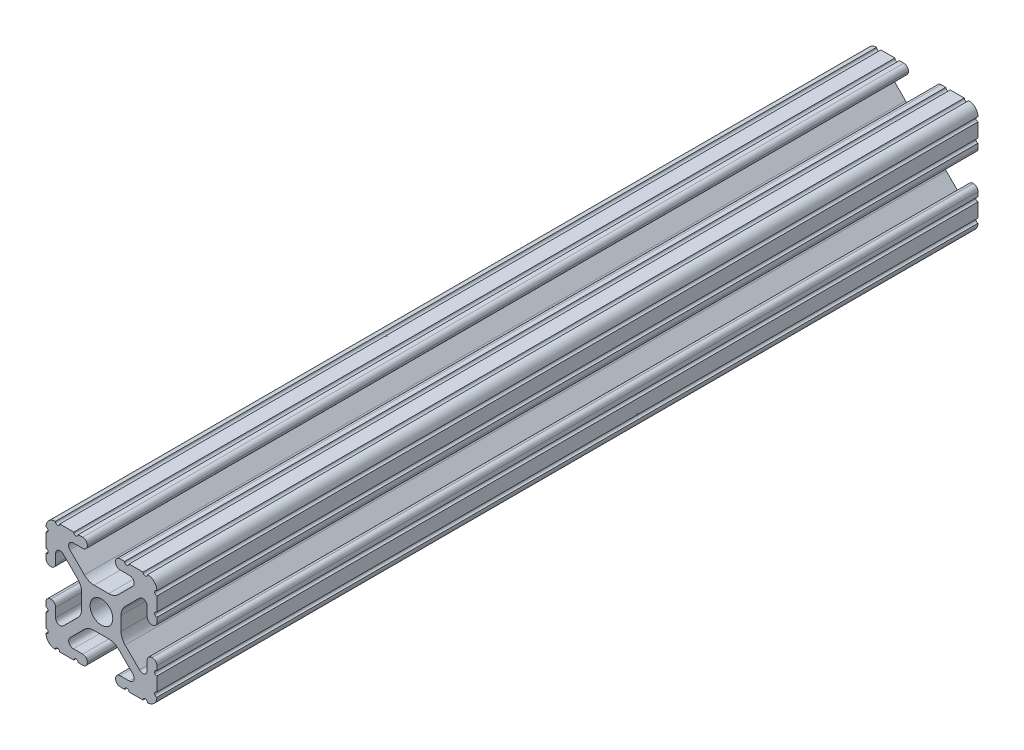
from build123d import *

# Parameters (mm, degrees)
SKETCH1_R               = 2.6035
BOSS_EXTRUDE1_DEPTH     = 304.8
SKETCH2_W               = 16.257599062
SKETCH2_H               = 27.586789262
CUT_EXTRUDE1_DEPTH      = 1.778
CUT_EXTRUDE1_DEPTH_BACK = 26.162


with BuildPart() as part:
    # Sketch1 → Boss-Extrude1 (new body, symmetric)
    with BuildSketch(Plane.XY):
        with BuildLine():
            Line((-7.179650497, -8.645192506), (-3.952270251, -5.423690499))
            ThreePointArc((-3.952270251, -5.423690499), (-2.922936451, -4.736929036), (-1.709253557, -4.4958))
            Line((-1.709253557, -4.4958), (1.709253557, -4.4958))
            ThreePointArc((1.709253557, -4.4958), (2.922936451, -4.736929036), (3.952270251, -5.423690499))
            Line((3.952270251, -5.423690499), (7.179650497, -8.645192506))
            ThreePointArc((7.179650497, -8.645192506), (7.41473083, -9.822813117), (6.416408329, -10.4902))
            Line((6.416408329, -10.4902), (4.287512407, -10.4902))
            ThreePointArc((4.287512407, -10.4902), (3.54574862, -10.79744862), (3.2385, -11.539212407))
            Line((3.2385, -11.539212407), (3.2385, -11.650987593))
            ThreePointArc((3.2385, -11.650987593), (3.54574862, -12.39275138), (4.287512407, -12.7))
            Line((4.287512407, -12.7), (5.317126718, -12.7))
            ThreePointArc((5.317126718, -12.7), (5.825126718, -12.192), (6.333126718, -12.7))
            Line((6.333126718, -12.7), (9.550443118, -12.7))
            ThreePointArc((9.550443118, -12.7), (10.058366869, -12.192000006), (10.566443095, -12.699847501))
            ThreePointArc((10.566443095, -12.699847501), (12.082537762, -12.08250727), (12.699846982, -10.566399977))
            ThreePointArc((12.699846982, -10.566399977), (12.192000006, -10.058323491), (12.7, -9.5504))
            Line((12.7, -9.5504), (12.7, -6.3330836))
            ThreePointArc((12.7, -6.3330836), (12.192, -5.8250836), (12.7, -5.3170836))
            Line((12.7, -5.3170836), (12.7, -4.287469289))
            ThreePointArc((12.7, -4.287469289), (12.39275138, -3.545705502), (11.650987593, -3.238456882))
            Line((11.650987593, -3.238456882), (11.539212407, -3.238456882))
            ThreePointArc((11.539212407, -3.238456882), (10.79744862, -3.545705502), (10.4902, -4.287469289))
            Line((10.4902, -4.287469289), (10.4902, -6.402089023))
            ThreePointArc((10.4902, -6.402089023), (9.856505071, -7.351067942), (8.737131347, -7.129408934))
            Line((8.737131347, -7.129408934), (5.441005833, -3.840816462))
            ThreePointArc((5.441005833, -3.840816462), (4.750877967, -2.809883091), (4.5085, -1.593185507))
            Line((4.5085, -1.593185507), (4.5085, 1.593185507))
            ThreePointArc((4.5085, 1.593185507), (4.750877967, 2.809883091), (5.441005833, 3.840816462))
            Line((5.441005833, 3.840816462), (8.737131347, 7.129408934))
            ThreePointArc((8.737131347, 7.129408934), (9.856505071, 7.351067942), (10.4902, 6.402089023))
            Line((10.4902, 6.402089023), (10.4902, 4.287469289))
            ThreePointArc((10.4902, 4.287469289), (10.79744862, 3.545705502), (11.539212407, 3.238456882))
            Line((11.539212407, 3.238456882), (11.650987593, 3.238456882))
            ThreePointArc((11.650987593, 3.238456882), (12.39275138, 3.545705502), (12.7, 4.287469289))
            Line((12.7, 4.287469289), (12.7, 5.3170836))
            ThreePointArc((12.7, 5.3170836), (12.192, 5.8250836), (12.7, 6.3330836))
            Line((12.7, 6.3330836), (12.7, 9.5504))
            ThreePointArc((12.7, 9.5504), (12.192000006, 10.058323491), (12.699846982, 10.566399977))
            ThreePointArc((12.699846982, 10.566399977), (12.082537762, 12.08250727), (10.566443095, 12.699847501))
            ThreePointArc((10.566443095, 12.699847501), (10.058366869, 12.192000006), (9.550443118, 12.7))
            Line((9.550443118, 12.7), (6.333126718, 12.7))
            ThreePointArc((6.333126718, 12.7), (5.825126718, 12.192), (5.317126718, 12.7))
            Line((5.317126718, 12.7), (4.287512407, 12.7))
            ThreePointArc((4.287512407, 12.7), (3.54574862, 12.39275138), (3.2385, 11.650987593))
            Line((3.2385, 11.650987593), (3.2385, 11.539212407))
            ThreePointArc((3.2385, 11.539212407), (3.54574862, 10.79744862), (4.287512407, 10.4902))
            Line((4.287512407, 10.4902), (6.476788598, 10.4902))
            ThreePointArc((6.476788598, 10.4902), (7.432222385, 9.85140422), (7.207036008, 8.724370562))
            Line((7.207036008, 8.724370562), (3.898272566, 5.423169045))
            ThreePointArc((3.898272566, 5.423169045), (2.869120213, 4.736787962), (1.655778399, 4.4958))
            Line((1.655778399, 4.4958), (-1.655778399, 4.4958))
            ThreePointArc((-1.655778399, 4.4958), (-2.869120213, 4.736787962), (-3.898272566, 5.423169045))
            Line((-3.898272566, 5.423169045), (-7.207036008, 8.724370562))
            ThreePointArc((-7.207036008, 8.724370562), (-7.432222385, 9.85140422), (-6.476788598, 10.4902))
            Line((-6.476788598, 10.4902), (-4.287512407, 10.4902))
            ThreePointArc((-4.287512407, 10.4902), (-3.54574862, 10.79744862), (-3.2385, 11.539212407))
            Line((-3.2385, 11.539212407), (-3.2385, 11.650987593))
            ThreePointArc((-3.2385, 11.650987593), (-3.54574862, 12.39275138), (-4.287512407, 12.7))
            Line((-4.287512407, 12.7), (-5.317126718, 12.7))
            ThreePointArc((-5.317126718, 12.7), (-5.825126718, 12.192), (-6.333126718, 12.7))
            Line((-6.333126718, 12.7), (-9.550443118, 12.7))
            ThreePointArc((-9.550443118, 12.7), (-10.058366869, 12.192000006), (-10.566443095, 12.699847501))
            ThreePointArc((-10.566443095, 12.699847501), (-12.082537762, 12.08250727), (-12.699846982, 10.566399977))
            ThreePointArc((-12.699846982, 10.566399977), (-12.192000006, 10.058323491), (-12.7, 9.5504))
            Line((-12.7, 9.5504), (-12.7, 6.3330836))
            ThreePointArc((-12.7, 6.3330836), (-12.192, 5.8250836), (-12.7, 5.3170836))
            Line((-12.7, 5.3170836), (-12.7, 4.287469289))
            ThreePointArc((-12.7, 4.287469289), (-12.39275138, 3.545705502), (-11.650987593, 3.238456882))
            Line((-11.650987593, 3.238456882), (-11.539212407, 3.238456882))
            ThreePointArc((-11.539212407, 3.238456882), (-10.79744862, 3.545705502), (-10.4902, 4.287469289))
            Line((-10.4902, 4.287469289), (-10.4902, 6.402089023))
            ThreePointArc((-10.4902, 6.402089023), (-9.856505071, 7.351067942), (-8.737131347, 7.129408934))
            Line((-8.737131347, 7.129408934), (-5.441005833, 3.840816462))
            ThreePointArc((-5.441005833, 3.840816462), (-4.750877967, 2.809883091), (-4.5085, 1.593185507))
            Line((-4.5085, 1.593185507), (-4.5085, -1.593185507))
            ThreePointArc((-4.5085, -1.593185507), (-4.750877967, -2.809883091), (-5.441005833, -3.840816462))
            Line((-5.441005833, -3.840816462), (-8.737131347, -7.129408934))
            ThreePointArc((-8.737131347, -7.129408934), (-9.856505071, -7.351067942), (-10.4902, -6.402089023))
            Line((-10.4902, -6.402089023), (-10.4902, -4.287469289))
            ThreePointArc((-10.4902, -4.287469289), (-10.79744862, -3.545705502), (-11.539212407, -3.238456882))
            Line((-11.539212407, -3.238456882), (-11.650987593, -3.238456882))
            ThreePointArc((-11.650987593, -3.238456882), (-12.39275138, -3.545705502), (-12.7, -4.287469289))
            Line((-12.7, -4.287469289), (-12.7, -5.3170836))
            ThreePointArc((-12.7, -5.3170836), (-12.192, -5.8250836), (-12.7, -6.3330836))
            Line((-12.7, -6.3330836), (-12.7, -9.5504))
            ThreePointArc((-12.7, -9.5504), (-12.192000006, -10.058323491), (-12.699846982, -10.566399977))
            ThreePointArc((-12.699846982, -10.566399977), (-12.082537762, -12.08250727), (-10.566443095, -12.699847501))
            ThreePointArc((-10.566443095, -12.699847501), (-10.058366869, -12.192000006), (-9.550443118, -12.7))
            Line((-9.550443118, -12.7), (-6.333126718, -12.7))
            ThreePointArc((-6.333126718, -12.7), (-5.825126718, -12.192), (-5.317126718, -12.7))
            Line((-5.317126718, -12.7), (-4.287512407, -12.7))
            ThreePointArc((-4.287512407, -12.7), (-3.54574862, -12.39275138), (-3.2385, -11.650987593))
            Line((-3.2385, -11.650987593), (-3.2385, -11.539212407))
            ThreePointArc((-3.2385, -11.539212407), (-3.54574862, -10.79744862), (-4.287512407, -10.4902))
            Line((-4.287512407, -10.4902), (-6.416408329, -10.4902))
            ThreePointArc((-6.416408329, -10.4902), (-7.41473083, -9.822813117), (-7.179650497, -8.645192506))
        make_face()
        Circle(SKETCH1_R, mode=Mode.SUBTRACT)
    extrude(amount=BOSS_EXTRUDE1_DEPTH, both=True)

    # Sketch2 → Cut-Extrude1 (cut, two sides)
    with BuildSketch(Plane(origin=(12.7, 0, 0), x_dir=(0, 0, -1), z_dir=(1, 0, 0))) as cut_extrude1_sk:
        Polygon((-56.586481007, -14.234528627), (310.743066166, -14.234528627), (310.743066166, 13.643777343), (-56.586481007, 13.643777343), (-101.042247833, 13.643777343), (-101.042247833, -14.234528627), align=None)
        with Locations((-297.347005301, -0.441133996)):
            Rectangle(SKETCH2_W, SKETCH2_H)
    extrude(amount=CUT_EXTRUDE1_DEPTH, mode=Mode.SUBTRACT)
    extrude(cut_extrude1_sk.sketch, amount=-CUT_EXTRUDE1_DEPTH_BACK, mode=Mode.SUBTRACT)


solid = part.part
